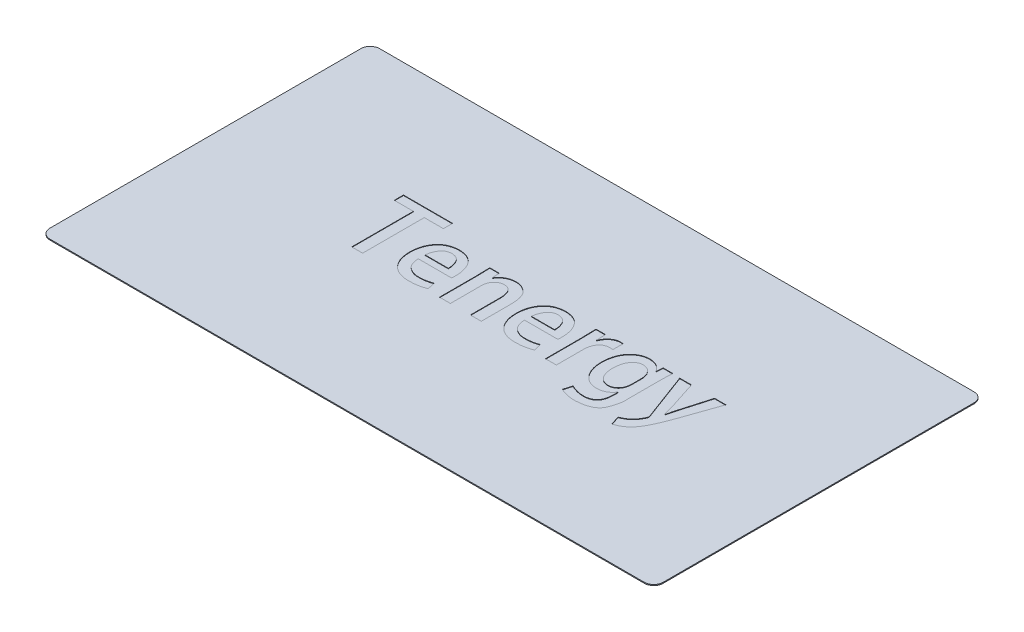
from build123d import *

# Parameters (mm, degrees)
SKETCH1_W           = 129.8
SKETCH1_H           = 69.8
BOSS_EXTRUDE1_DEPTH = 0.2
FILLET1_R           = 2
CUT_EXTRUDE4_DEPTH  = 0.1


with BuildPart() as part:
    # Sketch1 → Boss-Extrude1 (new body)
    with BuildSketch(Plane(origin=(0, 0, 0), x_dir=(1, 0, 0), z_dir=(0, 1, 0))):
        Rectangle(SKETCH1_W, SKETCH1_H)
    extrude(amount=BOSS_EXTRUDE1_DEPTH)

    # Fillet1
    fillet1_edges = [part.edges().sort_by_distance(p)[0] for p in [
        (64.9, 0.1, 34.9),
        (-64.9, 0.1, 34.9),
        (-64.9, 0.1, -34.9),
        (64.9, 0.1, -34.9),
    ]]
    fillet(fillet1_edges, radius=FILLET1_R)

    # Sketch3 → Cut-Extrude4 (cut)
    with BuildSketch(Plane(origin=(0, 0.2, 0), x_dir=(1, 0, 0), z_dir=(0, 1, 0))):
        Polygon((-23.164621775, 10.593061982), (-33.557770372, 10.593061982), (-33.557770372, 8.653439095), (-29.521787396, 8.653439095), (-29.521787396, -4.394933051), (-27.220196901, -4.394933051), (-27.220196901, 8.653439095), (-23.164621775, 8.653439095), align=None)
        with BuildLine():
            add(Edge.make_bspline(
                [(-14.155377092, -2.318093143), (-14.24504593, -2.35405218), (-14.429017705, -2.427828623), (-14.717931391, -2.523340731), (-15.024499813, -2.60799342), (-15.350376839, -2.683193285), (-15.70245614, -2.742160737), (-16.083481822, -2.788149939), (-16.496172354, -2.811838436), (-16.780828659, -2.817252878), (-16.928244889, -2.820056879)],
                knots=[0, 0, 0, 0, 0.000289779, 0.000594534, 0.000912247, 0.001243674, 0.001597358, 0.001982689, 0.002394478, 0.0028368, 0.0028368, 0.0028368, 0.0028368], degree=3))
            add(Edge.make_bspline(
                [(-16.928244889, -2.820056879), (-17.03979811, -2.818817613), (-17.259588658, -2.816375918), (-17.583007282, -2.785340754), (-17.894058404, -2.728532486), (-18.192987307, -2.646309267), (-18.479071535, -2.538193763), (-18.753757164, -2.407400307), (-19.01396507, -2.250727229), (-19.26239357, -2.072981388), (-19.491988133, -1.865526789), (-19.692398938, -1.623108046), (-19.868282709, -1.350766443), (-20.010428606, -1.045360725), (-20.131489193, -0.711045406), (-20.219767839, -0.344959117), (-20.283516478, 0.052162352), (-20.300803442, 0.327848057), (-20.309764787, 0.470760054)],
                knots=[0, 0, 0, 0, 0.000334575, 0.000659205, 0.00097332, 0.001282082, 0.001587955, 0.001889689, 0.002193507, 0.002497971, 0.002804946, 0.003118869, 0.003438875, 0.003774852, 0.004127205, 0.004503933, 0.004902829, 0.005332183, 0.005332183, 0.005332183, 0.005332183], degree=3))
            Line((-20.309764787, 0.470760054), (-13.293687856, 0.473591754))
            add(Edge.make_bspline(
                [(-13.293687856, 0.473591754), (-13.277493902, 0.602875542), (-13.242486608, 0.882354863), (-13.23941743, 1.164046795), (-13.237768017, 1.315431412)],
                knots=[0, 0, 0, 0, 0.000390562, 0.000844299, 0.000844299, 0.000844299, 0.000844299], degree=3))
            add(Edge.make_bspline(
                [(-13.237768017, 1.315431412), (-13.239271556, 1.488418291), (-13.242217833, 1.827396704), (-13.285294371, 2.326679978), (-13.361270554, 2.805050699), (-13.469917254, 3.264342202), (-13.607032385, 3.70424342), (-13.781825193, 4.123914824), (-13.988660136, 4.522949759), (-14.22524885, 4.901642404), (-14.499121776, 5.249423792), (-14.815889331, 5.555616841), (-15.174740511, 5.814727684), (-15.571416105, 6.033547597), (-16.013002663, 6.197614419), (-16.490857704, 6.326152131), (-17.010594919, 6.408912638), (-17.371062375, 6.42576428), (-17.557496705, 6.434479976)],
                knots=[0, 0, 0, 0, 0.000518831, 0.001016682, 0.001501782, 0.00197067, 0.002431443, 0.00288256, 0.003332607, 0.003778484, 0.004220271, 0.004657275, 0.005095528, 0.005544566, 0.006012012, 0.00650499, 0.007027371, 0.007586975, 0.007586975, 0.007586975, 0.007586975], degree=3))
            add(Edge.make_bspline(
                [(-17.557496705, 6.434479976), (-17.749564873, 6.42559322), (-18.123111453, 6.408309684), (-18.666917906, 6.326378916), (-19.17396921, 6.191859417), (-19.650629763, 6.018011026), (-20.088583877, 5.788242314), (-20.494945299, 5.516115207), (-20.863326862, 5.191168734), (-21.196056965, 4.822799591), (-21.493487462, 4.41825558), (-21.749117535, 3.980997407), (-21.966939473, 3.517695098), (-22.150802861, 3.028535831), (-22.287542629, 2.509454668), (-22.389902462, 1.963973413), (-22.453086255, 1.390591807), (-22.462167065, 0.999075699), (-22.466794664, 0.799558301)],
                knots=[0, 0, 0, 0, 0.000576576, 0.001121361, 0.001645929, 0.002148198, 0.002640091, 0.003125935, 0.003612028, 0.004109669, 0.004612529, 0.005115669, 0.005626644, 0.006146829, 0.006681072, 0.007234773, 0.007810721, 0.008409224, 0.008409224, 0.008409224, 0.008409224], degree=3))
            add(Edge.make_bspline(
                [(-22.466794664, 0.799558301), (-22.4624103, 0.601907132), (-22.453826635, 0.214947619), (-22.387625841, -0.350171895), (-22.280412173, -0.884904133), (-22.132515575, -1.389530759), (-21.946240397, -1.865146266), (-21.715895137, -2.310167254), (-21.440953034, -2.722604026), (-21.131149587, -3.106670058), (-20.777821137, -3.450550095), (-20.387760077, -3.753224165), (-19.959275667, -4.009458563), (-19.494122431, -4.219932942), (-18.990950538, -4.383953587), (-18.451974328, -4.504680229), (-17.875264275, -4.582764607), (-17.478386073, -4.596080979), (-17.274049941, -4.602937027)],
                knots=[0, 0, 0, 0, 0.000592838, 0.001160652, 0.001704308, 0.002227212, 0.002736194, 0.003234424, 0.003727336, 0.004220932, 0.004712016, 0.005203001, 0.00569883, 0.006206231, 0.006731488, 0.007283657, 0.007861311, 0.00847435, 0.00847435, 0.00847435, 0.00847435], degree=3))
            add(Edge.make_bspline(
                [(-17.274049941, -4.602937027), (-17.08877205, -4.600331958), (-16.729113799, -4.595275044), (-16.206299888, -4.552979106), (-15.714928637, -4.495906504), (-15.256387992, -4.41306427), (-14.83283803, -4.314447832), (-14.446731114, -4.204297932), (-14.099010017, -4.084898407), (-13.886229008, -3.988465005), (-13.784820272, -3.942506066)],
                knots=[0, 0, 0, 0, 0.000555736, 0.001078786, 0.001572748, 0.002039231, 0.002475822, 0.002876847, 0.003243503, 0.003577357, 0.003577357, 0.003577357, 0.003577357], degree=3))
            Line((-13.784820272, -3.942506066), (-14.155377092, -2.318093143))
        make_face()
        with BuildLine():
            add(Edge.make_bspline(
                [(-20.289189984, 1.902166214), (-20.269417537, 2.079629055), (-20.22969988, 2.436105336), (-20.086697444, 2.95970393), (-19.879580345, 3.470371156), (-19.660867496, 3.881150276), (-19.4482816, 4.188791029), (-19.264404971, 4.393774341), (-19.056836467, 4.567662789), (-18.832354626, 4.71804564), (-18.582980851, 4.833303622), (-18.313889703, 4.921728179), (-18.023731831, 4.981701492), (-17.822319239, 4.9977042), (-17.719061361, 5.005908284)],
                knots=[0, 0, 0, 0, 0.000535044, 0.001074762, 0.001621638, 0.002186046, 0.002466787, 0.002741731, 0.003009209, 0.003277287, 0.003549898, 0.003830453, 0.004125632, 0.004436158, 0.004436158, 0.004436158, 0.004436158], degree=3))
            add(Edge.make_bspline(
                [(-17.719061361, 5.005908284), (-17.611955766, 4.99910853), (-17.404677077, 4.985949143), (-17.108902685, 4.923556689), (-16.835902656, 4.841331181), (-16.591351885, 4.722828319), (-16.368467368, 4.581323436), (-16.175958357, 4.405769449), (-16.004541068, 4.205330441), (-15.821529414, 3.897631399), (-15.636860748, 3.487882352), (-15.483527037, 2.973869358), (-15.393939211, 2.442985498), (-15.39262741, 2.083914371), (-15.391963426, 1.902166214)],
                knots=[0, 0, 0, 0, 0.000321547, 0.000622281, 0.000904663, 0.001174712, 0.001434943, 0.001693874, 0.001953364, 0.002223175, 0.002764825, 0.003297494, 0.00382872, 0.004373204, 0.004373204, 0.004373204, 0.004373204], degree=3))
            Line((-15.391963426, 1.902166214), (-20.289189984, 1.902166214))
        make_face(mode=Mode.SUBTRACT)
        with BuildLine():
            add(Edge.make_bspline(
                [(-2.186181444, 2.284603439), (-2.195059491, 2.478542116), (-2.212251723, 2.854102039), (-2.277096928, 3.394141598), (-2.372432322, 3.889986474), (-2.498373748, 4.340676612), (-2.658978724, 4.745244481), (-2.853779027, 5.103389316), (-3.075873115, 5.420193861), (-3.338643855, 5.682123419), (-3.614237342, 5.908808001), (-3.898092396, 6.104523614), (-4.187811037, 6.271927977), (-4.487651413, 6.400618305), (-4.790946756, 6.50582208), (-5.102414089, 6.571375671), (-5.419041773, 6.615207828), (-5.63274043, 6.613774756), (-5.740601101, 6.613051437)],
                knots=[0, 0, 0, 0, 0.000582276, 0.00112757, 0.001630095, 0.002095751, 0.002529461, 0.002932803, 0.003316672, 0.00368548, 0.004041868, 0.004386242, 0.00471883, 0.005043757, 0.005363751, 0.005680108, 0.005997227, 0.006320406, 0.006320406, 0.006320406, 0.006320406], degree=3))
            add(Edge.make_bspline(
                [(-5.740601101, 6.613051437), (-5.931046943, 6.602747501), (-6.2978345, 6.582902722), (-6.82409194, 6.475840243), (-7.303683022, 6.311067319), (-7.730501296, 6.080500788), (-8.104527781, 5.812759727), (-8.428511917, 5.519970999), (-8.706380708, 5.210929927), (-8.84665853, 4.979907684), (-8.915204861, 4.867019369)],
                knots=[0, 0, 0, 0, 0.00057153, 0.001100734, 0.001605436, 0.002087296, 0.002550573, 0.002982055, 0.003395887, 0.003791344, 0.003791344, 0.003791344, 0.003791344], degree=3))
            Line((-8.915204861, 4.867019369), (-8.974728682, 4.868724479))
            Line((-8.974728682, 4.868724479), (-9.093776323, 6.391525612))
            Line((-9.093776323, 6.391525612), (-11.096751222, 6.391525612))
            add(Edge.make_bspline(
                [(-11.096751222, 6.391525612), (-11.087392647, 6.170591411), (-11.068230828, 5.718225404), (-11.047765107, 5.143891509), (-11.030663744, 4.661132019), (-11.027574039, 4.273659746), (-11.0194731, 3.863644936), (-11.020622324, 3.583010283), (-11.02121432, 3.438447677)],
                knots=[0, 0, 0, 0, 0.000663392, 0.001358305, 0.001724127, 0.002112491, 0.002520693, 0.002954367, 0.002954367, 0.002954367, 0.002954367], degree=3))
            Line((-11.02121432, 3.438447677), (-11.01838262, -4.317951235))
            Line((-11.01838262, -4.317951235), (-8.716792126, -4.317951235))
            Line((-8.716792126, -4.317951235), (-8.716792126, 2.186642688))
            add(Edge.make_bspline(
                [(-8.716792126, 2.186642688), (-8.711828539, 2.291322953), (-8.702166424, 2.495093509), (-8.660701723, 2.789927445), (-8.606747475, 3.066854899), (-8.525607042, 3.323380196), (-8.428295708, 3.561808399), (-8.3070078, 3.779538838), (-8.16882684, 3.979396684), (-8.009008205, 4.156229894), (-7.840158923, 4.315916449), (-7.660461299, 4.450416416), (-7.478736421, 4.570062548), (-7.288095934, 4.661985175), (-7.094006937, 4.737020697), (-6.894801832, 4.791606046), (-6.689256111, 4.823012484), (-6.550417609, 4.827771284), (-6.480397156, 4.83017129)],
                knots=[0, 0, 0, 0, 0.000314223, 0.000611667, 0.000892394, 0.001159556, 0.001417493, 0.001663619, 0.001905812, 0.002144733, 0.002377367, 0.002601863, 0.002817301, 0.003028996, 0.003235348, 0.00344094, 0.00364739, 0.003857447, 0.003857447, 0.003857447, 0.003857447], degree=3))
            add(Edge.make_bspline(
                [(-6.480397156, 4.83017129), (-6.391366773, 4.825610736), (-6.21878538, 4.816770309), (-5.971772475, 4.770331071), (-5.743828025, 4.702652258), (-5.536901715, 4.609293472), (-5.350194542, 4.492656983), (-5.186095722, 4.350263835), (-5.039665685, 4.185905202), (-4.878712229, 3.926700891), (-4.714954257, 3.56479706), (-4.576783884, 3.087683336), (-4.496373678, 2.563465446), (-4.492574424, 2.199132035), (-4.49060087, 2.009875985)],
                knots=[0, 0, 0, 0, 0.000267178, 0.000517912, 0.00075194, 0.000979016, 0.001196846, 0.001409903, 0.001628819, 0.001854475, 0.002322472, 0.002815783, 0.003340527, 0.003907768, 0.003907768, 0.003907768, 0.003907768], degree=3))
            Line((-4.49060087, 2.009875985), (-4.48776917, -4.317951235))
            Line((-4.48776917, -4.317951235), (-2.186181444, -4.317951235))
            Line((-2.186181444, -4.317951235), (-2.186181444, 2.284603439))
        make_face()
        with BuildLine():
            add(Edge.make_bspline(
                [(8.338958125, -2.318093143), (8.249289287, -2.35405218), (8.065317511, -2.427828623), (7.776403826, -2.523340731), (7.469835404, -2.60799342), (7.143958377, -2.683193285), (6.791879077, -2.742160737), (6.410853394, -2.788149939), (5.998162863, -2.811838436), (5.713506558, -2.817252878), (5.566090328, -2.820056879)],
                knots=[0, 0, 0, 0, 0.000289779, 0.000594534, 0.000912247, 0.001243674, 0.001597358, 0.001982689, 0.002394478, 0.0028368, 0.0028368, 0.0028368, 0.0028368], degree=3))
            add(Edge.make_bspline(
                [(5.566090328, -2.820056879), (5.454537107, -2.818817613), (5.234746559, -2.816375918), (4.911327935, -2.785340754), (4.600276813, -2.728532486), (4.30134791, -2.646309267), (4.015263681, -2.538193763), (3.740578053, -2.407400307), (3.480370147, -2.250727229), (3.231941647, -2.072981388), (3.002347084, -1.865526789), (2.801936279, -1.623108046), (2.626052508, -1.350766443), (2.483906611, -1.045360725), (2.362846024, -0.711045406), (2.274567378, -0.344959117), (2.210818738, 0.052162352), (2.193531774, 0.327848057), (2.18457043, 0.470760054)],
                knots=[0, 0, 0, 0, 0.000334575, 0.000659205, 0.00097332, 0.001282082, 0.001587955, 0.001889689, 0.002193507, 0.002497971, 0.002804946, 0.003118869, 0.003438875, 0.003774852, 0.004127205, 0.004503933, 0.004902829, 0.005332183, 0.005332183, 0.005332183, 0.005332183], degree=3))
            Line((2.18457043, 0.470760054), (9.20064736, 0.473591754))
            add(Edge.make_bspline(
                [(9.20064736, 0.473591754), (9.216841315, 0.602875542), (9.251848608, 0.882354863), (9.254917787, 1.164046795), (9.2565672, 1.315431412)],
                knots=[0, 0, 0, 0, 0.000390562, 0.000844299, 0.000844299, 0.000844299, 0.000844299], degree=3))
            add(Edge.make_bspline(
                [(9.2565672, 1.315431412), (9.255063661, 1.488418291), (9.252117384, 1.827396704), (9.209040846, 2.326679978), (9.133064662, 2.805050699), (9.024417963, 3.264342202), (8.887302832, 3.70424342), (8.712510024, 4.123914824), (8.505675081, 4.522949759), (8.269086367, 4.901642404), (7.995213441, 5.249423792), (7.678445886, 5.555616841), (7.319594706, 5.814727684), (6.922919112, 6.033547597), (6.481332554, 6.197614419), (6.003477513, 6.326152131), (5.483740297, 6.408912638), (5.123272841, 6.42576428), (4.936838511, 6.434479976)],
                knots=[0, 0, 0, 0, 0.000518831, 0.001016682, 0.001501782, 0.00197067, 0.002431443, 0.00288256, 0.003332607, 0.003778484, 0.004220271, 0.004657275, 0.005095528, 0.005544566, 0.006012012, 0.00650499, 0.007027371, 0.007586975, 0.007586975, 0.007586975, 0.007586975], degree=3))
            add(Edge.make_bspline(
                [(4.936838511, 6.434479976), (4.744770343, 6.42559322), (4.371223764, 6.408309684), (3.827417311, 6.326378916), (3.320366007, 6.191859417), (2.843705454, 6.018011026), (2.40575134, 5.788242314), (1.999389918, 5.516115207), (1.631008355, 5.191168734), (1.298278251, 4.822799591), (1.000847754, 4.41825558), (0.745217682, 3.980997407), (0.527395744, 3.517695098), (0.343532356, 3.028535831), (0.206792587, 2.509454668), (0.104432755, 1.963973413), (0.041248961, 1.390591807), (0.032168152, 0.999075699), (0.027540553, 0.799558301)],
                knots=[0, 0, 0, 0, 0.000576576, 0.001121361, 0.001645929, 0.002148198, 0.002640091, 0.003125935, 0.003612028, 0.004109669, 0.004612529, 0.005115669, 0.005626644, 0.006146829, 0.006681072, 0.007234773, 0.007810721, 0.008409224, 0.008409224, 0.008409224, 0.008409224], degree=3))
            add(Edge.make_bspline(
                [(0.027540553, 0.799558301), (0.031924917, 0.601907132), (0.040508581, 0.214947619), (0.106709376, -0.350171895), (0.213923043, -0.884904133), (0.361819642, -1.389530759), (0.54809482, -1.865146266), (0.77844008, -2.310167254), (1.053382183, -2.722604026), (1.36318563, -3.106670058), (1.71651408, -3.450550095), (2.10657514, -3.753224165), (2.53505955, -4.009458563), (3.000212785, -4.219932942), (3.503384679, -4.383953587), (4.042360889, -4.504680229), (4.619070942, -4.582764607), (5.015949144, -4.596080979), (5.220285276, -4.602937027)],
                knots=[0, 0, 0, 0, 0.000592838, 0.001160652, 0.001704308, 0.002227212, 0.002736194, 0.003234424, 0.003727336, 0.004220932, 0.004712016, 0.005203001, 0.00569883, 0.006206231, 0.006731488, 0.007283657, 0.007861311, 0.00847435, 0.00847435, 0.00847435, 0.00847435], degree=3))
            add(Edge.make_bspline(
                [(5.220285276, -4.602937027), (5.405563166, -4.600331958), (5.765221418, -4.595275044), (6.288035329, -4.552979106), (6.77940658, -4.495906504), (7.237947224, -4.41306427), (7.661497187, -4.314447832), (8.047604102, -4.204297932), (8.395325199, -4.084898407), (8.608106208, -3.988465005), (8.709514945, -3.942506066)],
                knots=[0, 0, 0, 0, 0.000555736, 0.001078786, 0.001572748, 0.002039231, 0.002475822, 0.002876847, 0.003243503, 0.003577357, 0.003577357, 0.003577357, 0.003577357], degree=3))
            Line((8.709514945, -3.942506066), (8.338958125, -2.318093143))
        make_face()
        with BuildLine():
            add(Edge.make_bspline(
                [(2.205145232, 1.902166214), (2.224917679, 2.079629055), (2.264635337, 2.436105336), (2.407637773, 2.95970393), (2.614754872, 3.470371156), (2.83346772, 3.881150276), (3.046053617, 4.188791029), (3.229930246, 4.393774341), (3.437498749, 4.567662789), (3.661980591, 4.71804564), (3.911354366, 4.833303622), (4.180445514, 4.921728179), (4.470603386, 4.981701492), (4.672015978, 4.9977042), (4.775273856, 5.005908284)],
                knots=[0, 0, 0, 0, 0.000535044, 0.001074762, 0.001621638, 0.002186046, 0.002466787, 0.002741731, 0.003009209, 0.003277287, 0.003549898, 0.003830453, 0.004125632, 0.004436158, 0.004436158, 0.004436158, 0.004436158], degree=3))
            add(Edge.make_bspline(
                [(4.775273856, 5.005908284), (4.882379451, 4.99910853), (5.08965814, 4.985949143), (5.385432532, 4.923556689), (5.658432561, 4.841331181), (5.902983332, 4.722828319), (6.125867849, 4.581323436), (6.31837686, 4.405769449), (6.489794149, 4.205330441), (6.672805803, 3.897631399), (6.857474469, 3.487882352), (7.010808179, 2.973869358), (7.100396006, 2.442985498), (7.101707807, 2.083914371), (7.102371791, 1.902166214)],
                knots=[0, 0, 0, 0, 0.000321547, 0.000622281, 0.000904663, 0.001174712, 0.001434943, 0.001693874, 0.001953364, 0.002223175, 0.002764825, 0.003297494, 0.00382872, 0.004373204, 0.004373204, 0.004373204, 0.004373204], degree=3))
            Line((7.102371791, 1.902166214), (2.205145232, 1.902166214))
        make_face(mode=Mode.SUBTRACT)
        with BuildLine():
            add(Edge.make_bspline(
                [(16.9318793, 6.560442168), (16.839651078, 6.576457716), (16.651284379, 6.609167834), (16.460135848, 6.61361577), (16.362577581, 6.615885905)],
                knots=[0, 0, 0, 0, 0.000280405, 0.000572699, 0.000572699, 0.000572699, 0.000572699], degree=3))
            add(Edge.make_bspline(
                [(16.362577581, 6.615885905), (16.21449492, 6.607797221), (15.92079482, 6.59175451), (15.490850352, 6.476291373), (15.082095645, 6.288305095), (14.694478535, 6.03532428), (14.335113841, 5.721836769), (14.026752042, 5.341560124), (13.756708543, 4.909987268), (13.626368005, 4.589684292), (13.559289082, 4.424842417)],
                knots=[0, 0, 0, 0, 0.000443954, 0.000880517, 0.001325754, 0.001788823, 0.002264786, 0.00275001, 0.003252679, 0.003785679, 0.003785679, 0.003785679, 0.003785679], degree=3))
            Line((13.559289082, 4.424842417), (13.479923988, 4.425335127))
            Line((13.479923988, 4.425335127), (13.400558894, 6.385781939))
            Line((13.400558894, 6.385781939), (11.397583995, 6.385781939))
            add(Edge.make_bspline(
                [(11.397583995, 6.385781939), (11.410620537, 6.134672815), (11.437232256, 5.622079417), (11.457341457, 4.831201464), (11.473268405, 3.991235739), (11.473171333, 3.412947068), (11.473120897, 3.112483898)],
                knots=[0, 0, 0, 0, 0.000754309, 0.001539784, 0.002373238, 0.003274603, 0.003274603, 0.003274603, 0.003274603], degree=3))
            Line((11.473120897, 3.112483898), (11.475952596, -4.39113254))
            Line((11.475952596, -4.39113254), (13.777543091, -4.39113254))
            Line((13.777543091, -4.39113254), (13.777543091, 1.329775369))
            add(Edge.make_bspline(
                [(13.777543091, 1.329775369), (13.781072206, 1.445985889), (13.787943406, 1.672248222), (13.817939062, 2.003032881), (13.871996174, 2.314620123), (13.945512685, 2.608528732), (14.03939742, 2.88434967), (14.151374296, 3.143873927), (14.288951388, 3.381573912), (14.441837475, 3.602188675), (14.614375485, 3.79927682), (14.801369684, 3.975157151), (15.009046568, 4.11975152), (15.229281149, 4.243314679), (15.467688027, 4.335430717), (15.718434785, 4.408448297), (15.986125136, 4.45027675), (16.169698989, 4.457834171), (16.263371214, 4.461690496)],
                knots=[0, 0, 0, 0, 0.000348756, 0.000679029, 0.000995438, 0.001296546, 0.001586964, 0.00186872, 0.002142946, 0.002409522, 0.0026727, 0.00292744, 0.003177532, 0.003429991, 0.003683165, 0.003942468, 0.004212279, 0.004493406, 0.004493406, 0.004493406, 0.004493406], degree=3))
            add(Edge.make_bspline(
                [(16.263371214, 4.461690496), (16.381736135, 4.459945533), (16.605142168, 4.456652029), (16.825747046, 4.421519681), (16.92947111, 4.405001143)],
                knots=[0, 0, 0, 0, 0.000354592, 0.000669269, 0.000669269, 0.000669269, 0.000669269], degree=3))
            Line((16.92947111, 4.405001143), (16.9318793, 6.560442168))
        make_face()
        with BuildLine():
            Line((25.619946136, 6.381903923), (25.520739769, 4.947857058))
            Line((25.520739769, 4.947857058), (25.481057222, 4.947857058))
            add(Edge.make_bspline(
                [(25.481057222, 4.947857058), (25.420477346, 5.055876812), (25.297602528, 5.274974449), (25.0586264, 5.576687846), (24.772004585, 5.855313479), (24.440321242, 6.112838783), (24.052091385, 6.332853559), (23.600079355, 6.485022497), (23.092103129, 6.585858433), (22.733095532, 6.603687793), (22.544551511, 6.613051437)],
                knots=[0, 0, 0, 0, 0.000371096, 0.000752698, 0.001149564, 0.001567962, 0.002009557, 0.002481085, 0.002992501, 0.00355816, 0.00355816, 0.00355816, 0.00355816], degree=3))
            add(Edge.make_bspline(
                [(22.544551511, 6.613051437), (22.395922437, 6.60787078), (22.1017034, 6.597615397), (21.668361851, 6.524121119), (21.249790055, 6.408674603), (20.84651639, 6.244332829), (20.458508386, 6.037980215), (20.085720691, 5.784541859), (19.728875292, 5.486340813), (19.389657226, 5.143333136), (19.073669121, 4.760748028), (18.801358201, 4.329872209), (18.564055203, 3.860995753), (18.373904197, 3.347308941), (18.217463189, 2.795926614), (18.101563076, 2.203517803), (18.028870836, 1.56935215), (18.010407608, 1.132319943), (18.000899879, 0.907268072)],
                knots=[0, 0, 0, 0, 0.000445742, 0.00088237, 0.001314939, 0.001746021, 0.00218603, 0.002630997, 0.003095893, 0.003578926, 0.00407651, 0.0045813, 0.005104826, 0.005650223, 0.006221782, 0.006822696, 0.007459063, 0.008134672, 0.008134672, 0.008134672, 0.008134672], degree=3))
            add(Edge.make_bspline(
                [(18.000899879, 0.907268072), (18.006899674, 0.71815426), (18.018657973, 0.347532108), (18.078424922, -0.195451733), (18.174399408, -0.711775403), (18.3050085, -1.201794073), (18.469052965, -1.666147473), (18.670072073, -2.104182887), (18.910055751, -2.51408719), (19.181337477, -2.895330043), (19.478269334, -3.244858996), (19.807746699, -3.54660891), (20.158467806, -3.807261834), (20.53327133, -4.024434288), (20.935058877, -4.191991322), (21.358762559, -4.316779509), (21.807461603, -4.398197561), (22.115259174, -4.413643366), (22.272442617, -4.421531098)],
                knots=[0, 0, 0, 0, 0.000567467, 0.001112113, 0.001636911, 0.002141573, 0.002631969, 0.003112635, 0.003585167, 0.004054706, 0.004514947, 0.004958258, 0.005391941, 0.005823674, 0.006254299, 0.006694664, 0.007146697, 0.007618447, 0.007618447, 0.007618447, 0.007618447], degree=3))
            add(Edge.make_bspline(
                [(22.272442617, -4.421531098), (22.44007871, -4.414327518), (22.766355708, -4.400306894), (23.2371388, -4.311030487), (23.673162509, -4.169273406), (24.071544042, -3.973252941), (24.427427658, -3.729504209), (24.749650754, -3.459136384), (25.021638666, -3.145961873), (25.169157062, -2.915514817), (25.242964708, -2.800215606)],
                knots=[0, 0, 0, 0, 0.000502852, 0.000978722, 0.001432273, 0.001874677, 0.002305488, 0.002723608, 0.003133441, 0.003543813, 0.003543813, 0.003543813, 0.003543813], degree=3))
            Line((25.242964708, -2.800215606), (25.282644487, -2.797502932))
            Line((25.282644487, -2.797502932), (25.282644487, -3.859213131))
            add(Edge.make_bspline(
                [(25.282644487, -3.859213131), (25.277843151, -4.002355633), (25.268612442, -4.277551334), (25.226091924, -4.674916932), (25.159544202, -5.0411969), (25.065702579, -5.376769569), (24.95068704, -5.682744544), (24.808447019, -5.957088227), (24.640869637, -6.201044662), (24.445071609, -6.411262512), (24.23312766, -6.595699815), (24.002585495, -6.753763553), (23.757075152, -6.885947528), (23.495047558, -6.994993934), (23.218262046, -7.080750912), (22.923290961, -7.135318827), (22.613489447, -7.171347049), (22.401048101, -7.172968857), (22.292283891, -7.173799179)],
                knots=[0, 0, 0, 0, 0.000429556, 0.000825835, 0.001197755, 0.001545056, 0.001869847, 0.002176651, 0.002469933, 0.002754793, 0.003036106, 0.003311283, 0.003591566, 0.003871088, 0.00416159, 0.004458993, 0.004769817, 0.005095891, 0.005095891, 0.005095891, 0.005095891], degree=3))
            add(Edge.make_bspline(
                [(22.292283891, -7.173799179), (22.143803612, -7.170425087), (21.853702195, -7.163832769), (21.429909538, -7.115537611), (21.02609512, -7.049524448), (20.644695076, -6.955940417), (20.290108957, -6.84205217), (19.962914067, -6.719933366), (19.663011553, -6.591753659), (19.47885014, -6.491155942), (19.389789024, -6.442506527)],
                knots=[0, 0, 0, 0, 0.000445336, 0.0008701, 0.001278303, 0.001672222, 0.00204693, 0.002394935, 0.002719862, 0.003024155, 0.003024155, 0.003024155, 0.003024155], degree=3))
            Line((19.389789024, -6.442506527), (18.883072572, -8.171578846))
            add(Edge.make_bspline(
                [(18.883072572, -8.171578846), (18.995241836, -8.233988637), (19.224338211, -8.361455434), (19.596096547, -8.519972761), (19.999694892, -8.651961144), (20.4301276, -8.760096322), (20.878506457, -8.848366266), (21.337742875, -8.908726606), (21.802992832, -8.951808275), (22.115501994, -8.955050897), (22.272442617, -8.956679327)],
                knots=[0, 0, 0, 0, 0.000384889, 0.000786104, 0.001210073, 0.001657613, 0.00211678, 0.002580178, 0.003046722, 0.00351738, 0.00351738, 0.00351738, 0.00351738], degree=3))
            add(Edge.make_bspline(
                [(22.272442617, -8.956679327), (22.422791674, -8.948742086), (22.716441243, -8.933239711), (23.14430866, -8.885227677), (23.550657617, -8.831386767), (23.934353245, -8.756366805), (24.296913664, -8.669529099), (24.637773638, -8.567817599), (24.956651201, -8.451114343), (25.25378323, -8.322145027), (25.529141836, -8.176904748), (25.780186457, -8.013942538), (26.015385578, -7.843475631), (26.22236454, -7.650489757), (26.410718075, -7.447016377), (26.575840337, -7.227599711), (26.71833905, -6.993616324), (26.877340145, -6.665948384), (27.04112732, -6.248683829), (27.213395408, -5.751434887), (27.351901123, -5.26108356), (27.461280465, -4.778890928), (27.535009645, -4.303349579), (27.577224694, -3.835739023), (27.591683048, -3.374331758), (27.571562015, -3.070371239), (27.56155924, -2.919263247)],
                knots=[0, 0, 0, 0, 0.000451571, 0.000881971, 0.001291245, 0.001680931, 0.002054231, 0.002409344, 0.002747407, 0.003072334, 0.003380457, 0.003680027, 0.003969712, 0.004250568, 0.004527418, 0.004800662, 0.005072889, 0.005347963, 0.005892211, 0.006416587, 0.00692624, 0.007419991, 0.007899049, 0.008368665, 0.008827989, 0.00928207, 0.00928207, 0.00928207, 0.00928207], degree=3))
            Line((27.56155924, -2.919263247), (27.564390939, 3.274460991))
            add(Edge.make_bspline(
                [(27.564390939, 3.274460991), (27.563896554, 3.447228407), (27.562947913, 3.778739435), (27.569429842, 4.253855926), (27.577551104, 4.686605299), (27.588937054, 5.079667217), (27.602785642, 5.440632458), (27.621031332, 5.774044885), (27.635836205, 6.085172372), (27.652637254, 6.284291295), (27.660765607, 6.380625091)],
                knots=[0, 0, 0, 0, 0.000518295, 0.000994519, 0.001425442, 0.001816763, 0.002174187, 0.002509087, 0.002818511, 0.003108515, 0.003108515, 0.003108515, 0.003108515], degree=3))
            Line((27.660765607, 6.380625091), (25.619946136, 6.381903923))
        make_face()
        with BuildLine():
            add(Edge.make_bspline(
                [(25.262803213, 0.082147344), (25.256107293, -0.028337281), (25.243138241, -0.24233038), (25.21014647, -0.553182718), (25.144996353, -0.839362879), (25.068101594, -1.106483468), (24.963653947, -1.349755061), (24.847314498, -1.577654184), (24.699631819, -1.777964706), (24.539264629, -1.960379249), (24.362042069, -2.118109863), (24.178865099, -2.257807929), (23.987234051, -2.374002813), (23.791011146, -2.472675916), (23.585788598, -2.545089291), (23.374660222, -2.600564052), (23.15581358, -2.631400025), (23.007602419, -2.636220461), (22.932873578, -2.63865095)],
                knots=[0, 0, 0, 0, 0.000332117, 0.000643263, 0.000936257, 0.001211551, 0.001475811, 0.001729413, 0.001977198, 0.00222012, 0.00245693, 0.002687656, 0.002910302, 0.003128335, 0.003345315, 0.003561869, 0.003782339, 0.004006549, 0.004006549, 0.004006549, 0.004006549], degree=3))
            add(Edge.make_bspline(
                [(22.932873578, -2.63865095), (22.830648013, -2.633165013), (22.631581598, -2.622482108), (22.341569448, -2.572034914), (22.071198233, -2.48532544), (21.81748269, -2.372472876), (21.582055776, -2.22884501), (21.365216368, -2.055108727), (21.168530996, -1.84813704), (20.991526603, -1.613189782), (20.833202672, -1.354482937), (20.693492313, -1.076185895), (20.577289346, -0.775899754), (20.482757478, -0.457037973), (20.404105869, -0.119481407), (20.352717436, 0.238053735), (20.316834227, 0.61553706), (20.312969433, 0.874108986), (20.310991008, 1.006474439)],
                knots=[0, 0, 0, 0, 0.000306961, 0.000597753, 0.000880135, 0.00115671, 0.001428937, 0.001705163, 0.001987829, 0.002283186, 0.00258605, 0.002896615, 0.003216118, 0.003550598, 0.003893709, 0.004254889, 0.004633405, 0.005030392, 0.005030392, 0.005030392, 0.005030392], degree=3))
            add(Edge.make_bspline(
                [(20.310991008, 1.006474439), (20.315158069, 1.150164357), (20.32325856, 1.429488063), (20.359994339, 1.836590982), (20.418636955, 2.22028437), (20.501517042, 2.580776216), (20.601782967, 2.91906239), (20.727296607, 3.232968286), (20.874786764, 3.52360169), (21.044028042, 3.789324443), (21.231844392, 4.02778607), (21.431629656, 4.239647583), (21.650453531, 4.416127679), (21.880258251, 4.566831561), (22.128679016, 4.679288872), (22.39039796, 4.76183846), (22.665965607, 4.818336731), (22.856061434, 4.826182262), (22.952714852, 4.83017129)],
                knots=[0, 0, 0, 0, 0.000431175, 0.000838175, 0.00122543, 0.001594673, 0.001947072, 0.002282881, 0.0026074, 0.002923491, 0.003226288, 0.00351697, 0.003794979, 0.00406781, 0.004339225, 0.004609942, 0.00489011, 0.005179906, 0.005179906, 0.005179906, 0.005179906], degree=3))
            add(Edge.make_bspline(
                [(22.952714852, 4.83017129), (23.037953475, 4.826493517), (23.205688866, 4.819256275), (23.448342842, 4.774691877), (23.678614116, 4.712981236), (23.895089318, 4.626911633), (24.099883902, 4.520575594), (24.287590996, 4.38689931), (24.466275853, 4.237177794), (24.625534202, 4.060150905), (24.771532854, 3.869640837), (24.90138349, 3.666601027), (25.008025265, 3.451259954), (25.096788251, 3.224495523), (25.167788666, 2.98668212), (25.218251676, 2.737161361), (25.24978261, 2.476438576), (25.256521769, 2.299078506), (25.259971513, 2.20828872)],
                knots=[0, 0, 0, 0, 0.000255668, 0.000503113, 0.000738288, 0.000969883, 0.001200645, 0.001428674, 0.00165987, 0.001898589, 0.00214123, 0.002379494, 0.00262034, 0.002860886, 0.003109302, 0.0033639, 0.003623714, 0.003896192, 0.003896192, 0.003896192, 0.003896192], degree=3))
            Line((25.259971513, 2.20828872), (25.262803213, 0.082147344))
        make_face(mode=Mode.SUBTRACT)
        with BuildLine():
            Line((36.625469842, 6.255905746), (34.885956496, 0.219505535))
            add(Edge.make_bspline(
                [(34.885956496, 0.219505535), (34.835939494, 0.034900601), (34.735755278, -0.33486368), (34.585252067, -0.883086125), (34.450434528, -1.414208303), (34.361544554, -1.759047074), (34.318930101, -1.924365104)],
                knots=[0, 0, 0, 0, 0.000573785, 0.001149294, 0.001705464, 0.002217633, 0.002217633, 0.002217633, 0.002217633], degree=3))
            Line((34.318930101, -1.924365104), (34.260513495, -1.922538201))
            add(Edge.make_bspline(
                [(34.260513495, -1.922538201), (34.21787115, -1.756793641), (34.128461212, -1.409270286), (33.986019554, -0.876149208), (33.83858795, -0.326499341), (33.727523535, 0.03831792), (33.672671479, 0.218492434)],
                knots=[0, 0, 0, 0, 0.000513421, 0.001076511, 0.001655499, 0.002220476, 0.002220476, 0.002220476, 0.002220476], degree=3))
            Line((33.672671479, 0.218492434), (31.719651303, 6.255905746))
            Line((31.719651303, 6.255905746), (29.236729617, 6.255905746))
            Line((29.236729617, 6.255905746), (32.931447118, -3.63617319))
            add(Edge.make_bspline(
                [(32.931447118, -3.63617319), (32.95047664, -3.684226587), (32.985909823, -3.77370255), (33.026156969, -3.900048714), (33.049805482, -4.008739066), (33.047348055, -4.074705656), (33.046254129, -4.104070722)],
                knots=[0, 0, 0, 0, 0.000154965, 0.000288546, 0.000398068, 0.000485937, 0.000485937, 0.000485937, 0.000485937], degree=3))
            add(Edge.make_bspline(
                [(33.046254129, -4.104070722), (33.045689456, -4.135447475), (33.044399738, -4.207112191), (33.006499165, -4.325107717), (32.954221003, -4.468416968), (32.874413476, -4.636558039), (32.77712236, -4.831866097), (32.649071821, -5.049819229), (32.50370222, -5.296388664), (32.332378336, -5.562164975), (32.140099823, -5.840263711), (31.904841134, -6.102012361), (31.642438553, -6.354394671), (31.34647163, -6.590494593), (31.021773208, -6.819230242), (30.664332159, -7.03345792), (30.275494315, -7.235712441), (30.000946783, -7.354090783), (29.860312498, -7.414728929)],
                knots=[0, 0, 0, 0, 9.3709e-05, 0.000214032, 0.000368296, 0.000552209, 0.00077151, 0.001022884, 0.001310174, 0.00163018, 0.001971542, 0.002322982, 0.00268384, 0.003062769, 0.003457524, 0.003874605, 0.004311977, 0.004771301, 0.004771301, 0.004771301, 0.004771301], degree=3))
            Line((29.860312498, -7.414728929), (30.449220208, -9.322325653))
            add(Edge.make_bspline(
                [(30.449220208, -9.322325653), (30.522530978, -9.305593476), (30.683284641, -9.268903659), (30.936234133, -9.18081383), (31.223750529, -9.06659466), (31.541855455, -8.924310548), (31.881634038, -8.743443201), (32.233571328, -8.518473167), (32.592671486, -8.248157876), (32.828169544, -8.046277789), (32.94988223, -7.941939911)],
                knots=[0, 0, 0, 0, 0.000225443, 0.000494344, 0.000802259, 0.001153664, 0.001539152, 0.001955896, 0.002405443, 0.002886309, 0.002886309, 0.002886309, 0.002886309], degree=3))
            add(Edge.make_bspline(
                [(32.94988223, -7.941939911), (33.028186044, -7.863365547), (33.188254501, -7.702744032), (33.417432313, -7.441642605), (33.640085213, -7.156975025), (33.863396507, -6.853630662), (34.076672417, -6.524807644), (34.286653932, -6.176027944), (34.491742747, -5.805372241), (34.692298794, -5.410339662), (34.894600246, -4.988858766), (35.097740369, -4.537232001), (35.308012913, -4.055944121), (35.520299723, -3.54268257), (35.735024188, -2.997765979), (35.956618783, -2.421589211), (36.182876296, -1.814186009), (36.331881998, -1.397328312), (36.407932754, -1.184569049)],
                knots=[0, 0, 0, 0, 0.000332733, 0.000680172, 0.001041397, 0.001416716, 0.001809798, 0.00221667, 0.002637891, 0.003080305, 0.003545581, 0.004040315, 0.004565847, 0.005121186, 0.005706488, 0.006322898, 0.006973129, 0.007650952, 0.007650952, 0.007650952, 0.007650952], degree=3))
            Line((36.407932754, -1.184569049), (39.009971283, 6.255905746))
            Line((39.009971283, 6.255905746), (36.625469842, 6.255905746))
        make_face()
    extrude(amount=-CUT_EXTRUDE4_DEPTH, mode=Mode.SUBTRACT)


solid = part.part
